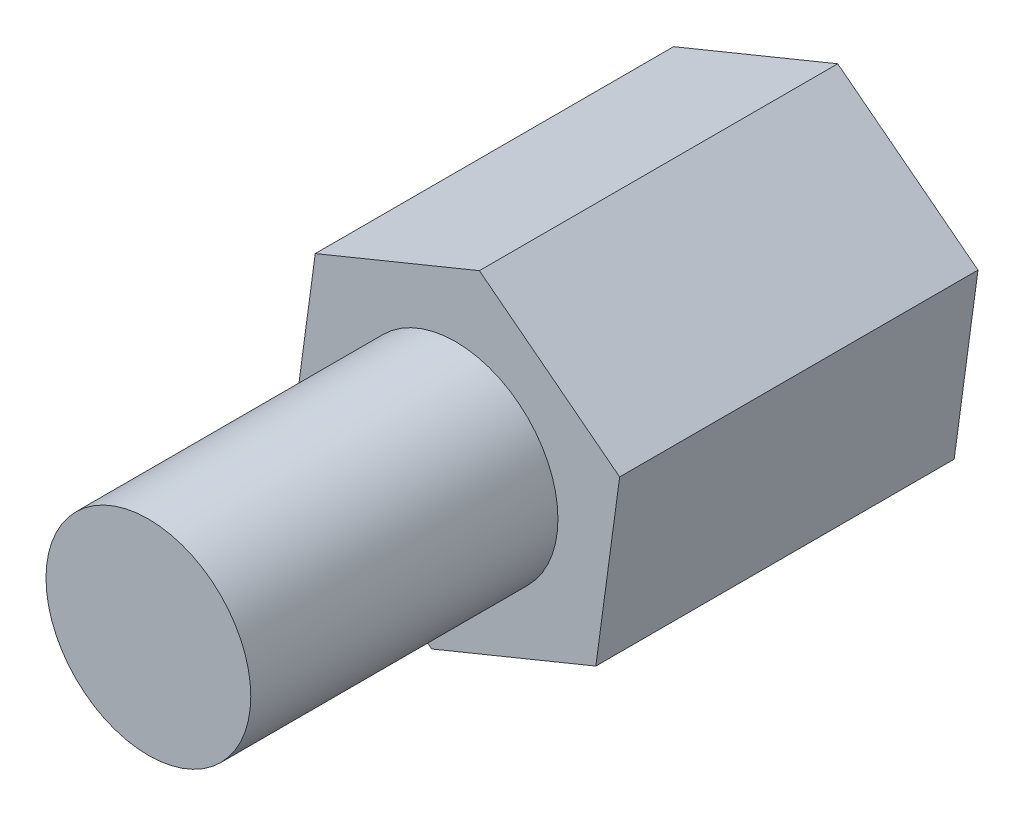
from build123d import *

# Parameters (mm, degrees)
EXTRUDE_1_DEPTH     = 7
SKETCH_2_R          = 2
EXTRUDE_2_DEPTH     = 6
SKETCH_3_R          = 2
CUT_EXTRUDE_1_DEPTH = 4


with BuildPart() as part:
    # 草图1 → 凸台-拉伸1 (new body)
    with BuildSketch(Plane.XY):
        Polygon((2.740200821, -2.119268615), (3.205440868, 1.313449215), (0.465240048, 3.43271783), (-2.740200821, 2.119268615), (-3.205440868, -1.313449215), (-0.465240048, -3.43271783), align=None)
    extrude(amount=EXTRUDE_1_DEPTH)

    # 草图2 → 凸台-拉伸2 (add)
    with BuildSketch(Plane.XY.offset(7)):
        Circle(SKETCH_2_R)
    extrude(amount=EXTRUDE_2_DEPTH)

    # 草图3 → 切除-拉伸1 (cut)
    with BuildSketch(Plane(origin=(0, 0, 0), x_dir=(-1, 0, 0), z_dir=(0, 0, -1))):
        Circle(SKETCH_3_R)
    extrude(amount=-CUT_EXTRUDE_1_DEPTH, mode=Mode.SUBTRACT)


solid = part.part
